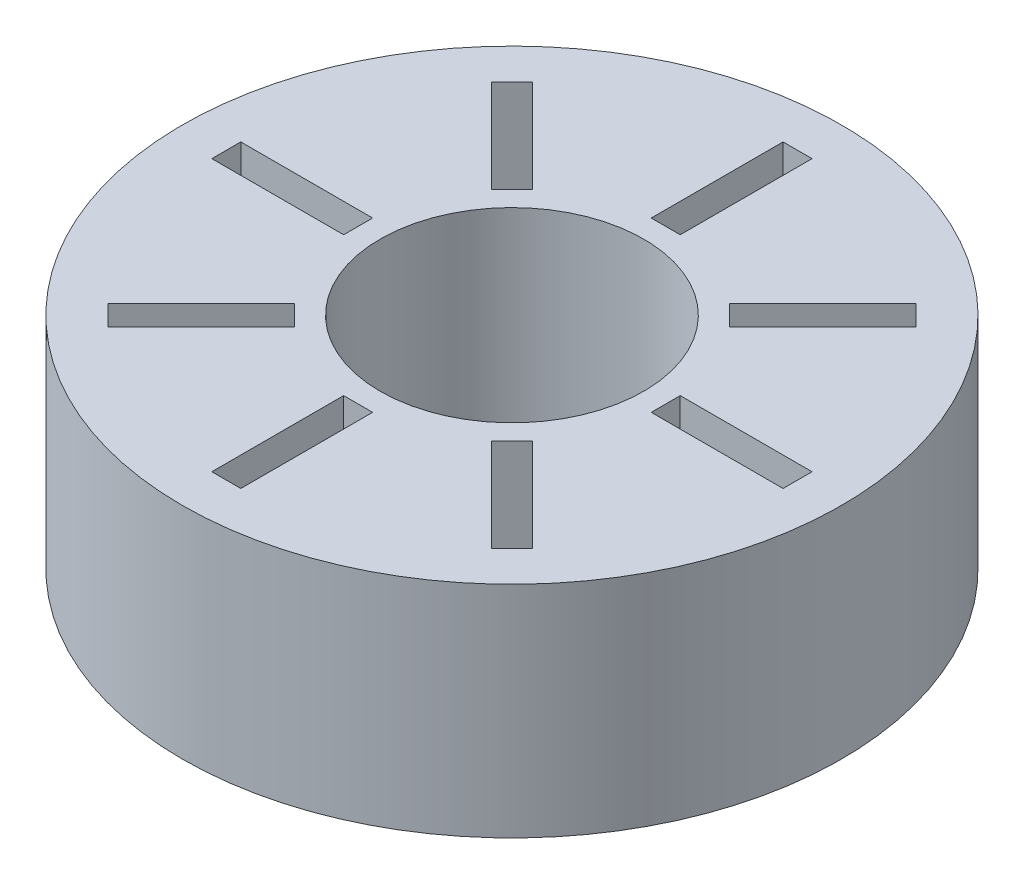
from build123d import *

# Parameters (mm, degrees)
SKETCH_1_R               = 7.5
SKETCH_1_R_2             = 3
EXTRUDE_1_DEPTH          = 5
SKETCH_2_W               = 0.65965233
SKETCH_2_H               = 3
CUT_EXTRUDE_1_DEPTH      = 10
PATTERN_CIRCULAR_1_COUNT = 8


with BuildPart() as part:
    # Эскиз1 → Бобышка-Вытянуть1 (new body)
    with BuildSketch(Plane(origin=(0, 0, 0), x_dir=(1, 0, 0), z_dir=(0, 1, 0))):
        Circle(SKETCH_1_R)
        Circle(SKETCH_1_R_2, mode=Mode.SUBTRACT)
    extrude(amount=EXTRUDE_1_DEPTH)

    # Эскиз2 → Вырез-Вытянуть1 (cut)
    with BuildSketch(Plane(origin=(0, 5, 0), x_dir=(1, 0, 0), z_dir=(0, 1, 0))):
        with Locations((0, 5)):
            Rectangle(SKETCH_2_W, SKETCH_2_H)
    cut_extrude_1 = extrude(amount=-CUT_EXTRUDE_1_DEPTH, mode=Mode.SUBTRACT)

    # Круговой массив1: Вырез-Вытянуть1 ×8 about axis
    pattern_circular_1_axis = Axis((0, 0, 0), (0, 1, 0))
    for i in range(1, PATTERN_CIRCULAR_1_COUNT):
        add(cut_extrude_1.rotate(pattern_circular_1_axis, i * 360 / PATTERN_CIRCULAR_1_COUNT), mode=Mode.SUBTRACT)


solid = part.part
